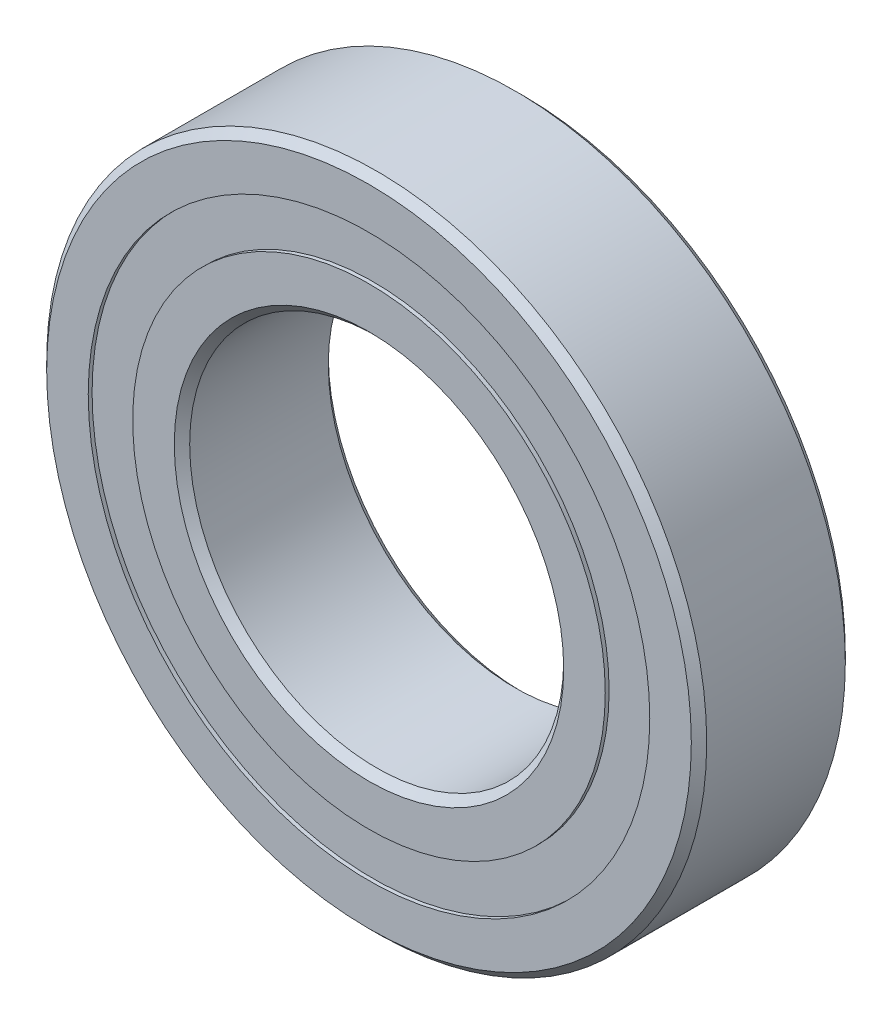
from build123d import *

# Parameters (mm, degrees)
CIRPATTERN1_COUNT = 12


with BuildPart() as part:
    # Sketch6 → Revolve1 (revolve)
    with BuildSketch(Plane(origin=(0, 0, 0), x_dir=(0, 0, -1), z_dir=(1, 0, 0))):
        with BuildLine():
            Line((-3.4999999999999996, 14.649999999999997), (-3.4999999999999996, 12.760989010989016))
            Line((-3.4999999999999996, 12.760989010989016), (-1.5555555555555556, 12.760989010989016))
            ThreePointArc((-1.5555555555555556, 12.760989010989016), (1.1e-16, 13.605222861750121), (1.5555555555555556, 12.760989010989016))
            Line((1.5555555555555556, 12.760989010989016), (3.4999999999999996, 12.760989010989016))
            Line((3.4999999999999996, 12.760989010989016), (3.4999999999999996, 14.649999999999997))
            Line((3.4999999999999996, 14.649999999999997), (3.1499999999999972, 15))
            Line((3.1499999999999972, 15), (-3.1499999999999972, 15))
            Line((-3.1499999999999972, 15), (-3.4999999999999996, 14.649999999999997))
        make_face()
        with BuildLine():
            Line((-3.4999999999999996, 8.85000000000001), (-3.4999999999999996, 10.73901098901099))
            Line((-3.4999999999999996, 10.73901098901099), (-1.555555555555556, 10.73901098901099))
            ThreePointArc((-1.555555555555556, 10.73901098901099), (1.1e-16, 9.894777138249886), (1.5555555555555556, 10.73901098901099))
            Line((1.5555555555555556, 10.73901098901099), (3.4999999999999996, 10.73901098901099))
            Line((3.4999999999999996, 10.73901098901099), (3.4999999999999996, 8.85000000000001))
            Line((3.4999999999999996, 8.85000000000001), (3.149999999999999, 8.500000000000007))
            Line((3.149999999999999, 8.500000000000007), (-3.149999999999999, 8.500000000000007))
            Line((-3.149999999999999, 8.500000000000007), (-3.4999999999999996, 8.85000000000001))
        make_face()
    revolve(axis=Axis((0, 0, 3.4999999999999996), (0, 0, -1)))



with BuildPart() as body_2:
    # Sketch4 → Revolve2 (revolve)
    with BuildSketch(Plane(origin=(0, 0, 0), x_dir=(0, 0, -1), z_dir=(1, 0, 0))):
        with BuildLine():
            Line((-1.8552228617501176, 11.750000000000004), (1.8552228617501176, 11.750000000000004))
            ThreePointArc((1.8552228617501176, 11.750000000000004), (1.1e-16, 13.605222861750121), (-1.8552228617501176, 11.750000000000004))
        make_face()
    revolve(axis=Axis((0, 11.750000000000004, 1.8552228617501176), (0, 0, -1)))


with BuildPart() as cirpattern1_1:
    # CirPattern1: pattern copy
    add(body_2.part.rotate(Axis((0, 0, -3.4999999999999996), (0, 0, 1)), 1 * 360 / CIRPATTERN1_COUNT))


with BuildPart() as cirpattern1_2:
    # CirPattern1: pattern copy
    add(body_2.part.rotate(Axis((0, 0, -3.4999999999999996), (0, 0, 1)), 2 * 360 / CIRPATTERN1_COUNT))


with BuildPart() as cirpattern1_3:
    # CirPattern1: pattern copy
    add(body_2.part.rotate(Axis((0, 0, -3.4999999999999996), (0, 0, 1)), 3 * 360 / CIRPATTERN1_COUNT))


with BuildPart() as cirpattern1_4:
    # CirPattern1: pattern copy
    add(body_2.part.rotate(Axis((0, 0, -3.4999999999999996), (0, 0, 1)), 4 * 360 / CIRPATTERN1_COUNT))


with BuildPart() as cirpattern1_5:
    # CirPattern1: pattern copy
    add(body_2.part.rotate(Axis((0, 0, -3.4999999999999996), (0, 0, 1)), 5 * 360 / CIRPATTERN1_COUNT))


with BuildPart() as cirpattern1_6:
    # CirPattern1: pattern copy
    add(body_2.part.rotate(Axis((0, 0, -3.4999999999999996), (0, 0, 1)), 6 * 360 / CIRPATTERN1_COUNT))


with BuildPart() as cirpattern1_7:
    # CirPattern1: pattern copy
    add(body_2.part.rotate(Axis((0, 0, -3.4999999999999996), (0, 0, 1)), 7 * 360 / CIRPATTERN1_COUNT))


with BuildPart() as cirpattern1_8:
    # CirPattern1: pattern copy
    add(body_2.part.rotate(Axis((0, 0, -3.4999999999999996), (0, 0, 1)), 8 * 360 / CIRPATTERN1_COUNT))


with BuildPart() as cirpattern1_9:
    # CirPattern1: pattern copy
    add(body_2.part.rotate(Axis((0, 0, -3.4999999999999996), (0, 0, 1)), 9 * 360 / CIRPATTERN1_COUNT))


with BuildPart() as cirpattern1_10:
    # CirPattern1: pattern copy
    add(body_2.part.rotate(Axis((0, 0, -3.4999999999999996), (0, 0, 1)), 10 * 360 / CIRPATTERN1_COUNT))


with BuildPart() as cirpattern1_11:
    # CirPattern1: pattern copy
    add(body_2.part.rotate(Axis((0, 0, -3.4999999999999996), (0, 0, 1)), 11 * 360 / CIRPATTERN1_COUNT))


with BuildPart() as part_1:
    add(part.part)

    add(body_2.part)  # Revolve3 merges body 2

    add(cirpattern1_1.part)  # Revolve3 merges CirPattern1_1

    add(cirpattern1_2.part)  # Revolve3 merges CirPattern1_2

    add(cirpattern1_3.part)  # Revolve3 merges CirPattern1_3

    add(cirpattern1_4.part)  # Revolve3 merges CirPattern1_4

    add(cirpattern1_5.part)  # Revolve3 merges CirPattern1_5

    add(cirpattern1_6.part)  # Revolve3 merges CirPattern1_6

    add(cirpattern1_7.part)  # Revolve3 merges CirPattern1_7

    add(cirpattern1_8.part)  # Revolve3 merges CirPattern1_8

    add(cirpattern1_9.part)  # Revolve3 merges CirPattern1_9

    add(cirpattern1_10.part)  # Revolve3 merges CirPattern1_10

    add(cirpattern1_11.part)  # Revolve3 merges CirPattern1_11
    # Sketch5 → Revolve3 (revolve)
    with BuildSketch(Plane(origin=(0, 0, 0), x_dir=(0, 0, -1), z_dir=(1, 0, 0))):
        Polygon((-3.325000000000007, 12.760989010989016), (-1.8552228617501176, 12.760989010989016), (-1.8552228617501167, 10.73901098901099), (-3.325000000000006, 10.73901098901099), align=None)
        Polygon((3.325000000000007, 12.760989010989016), (1.8552228617501176, 12.760989010989016), (1.8552228617501185, 10.73901098901099), (3.325000000000007, 10.73901098901099), align=None)
    revolve(axis=Axis((0, 0, 3.4999999999999996), (0, 0, -1)))


solid = part_1.part
